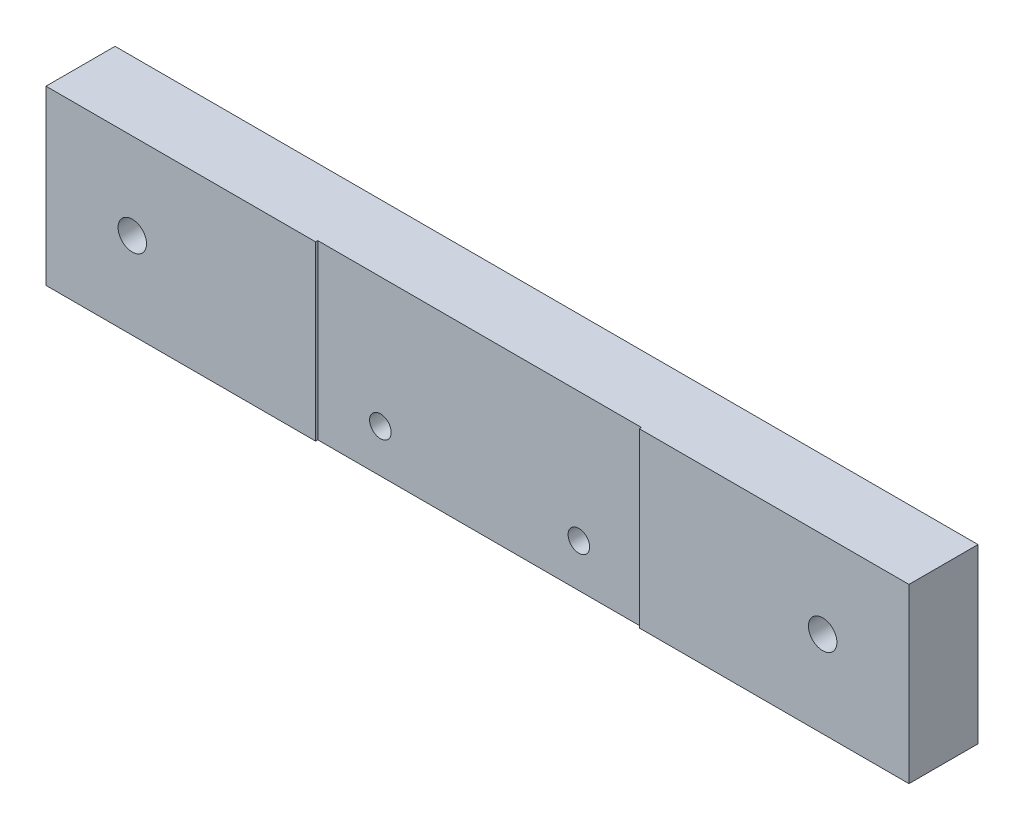
from build123d import *

# Parameters (mm, degrees)
SKETCH1_W                                           = 200
SKETCH1_H                                           = 40
EXTRUDE1_DEPTH                                      = 16
SKETCH2_W                                           = 75
SKETCH2_H                                           = 40
EXTRUDE2_DEPTH                                      = 0.5
M6_TAPPED_HOLE1_D                                   = 5
CBORE_FOR_M6_HEX_SOCKET_HEAD_CAP_SCREW1_D           = 6.6
CBORE_FOR_M6_HEX_SOCKET_HEAD_CAP_SCREW1_CBORE_D     = 11
CBORE_FOR_M6_HEX_SOCKET_HEAD_CAP_SCREW1_CBORE_DEPTH = 6.4


with BuildPart() as part:
    # Sketch1 → Extrude1 (new body)
    with BuildSketch(Plane.XY):
        Rectangle(SKETCH1_W, SKETCH1_H)
    extrude(amount=EXTRUDE1_DEPTH)

    # Sketch2 → Extrude2 (cut)
    with BuildSketch(Plane(origin=(0, 0, 16), x_dir=(-1, 0, 0), z_dir=(0, 0, -1))):
        Rectangle(SKETCH2_W, SKETCH2_H)
    extrude(amount=EXTRUDE2_DEPTH, mode=Mode.SUBTRACT)

    # M6 Tapped Hole1 (through all)
    with Locations(Plane.XY.offset(15.5)):
        with Locations((-23, -10), (23, -10)):
            Hole(M6_TAPPED_HOLE1_D / 2)

    # CBORE for M6 Hex Socket Head Cap Screw1 (through all)
    with Locations(Plane(origin=(0, 0, 0), x_dir=(-1, 0, 0), z_dir=(0, 0, -1))):
        with Locations((-80, 0), (80, 0)):
            CounterBoreHole(CBORE_FOR_M6_HEX_SOCKET_HEAD_CAP_SCREW1_D / 2, CBORE_FOR_M6_HEX_SOCKET_HEAD_CAP_SCREW1_CBORE_D / 2, CBORE_FOR_M6_HEX_SOCKET_HEAD_CAP_SCREW1_CBORE_DEPTH)


solid = part.part
